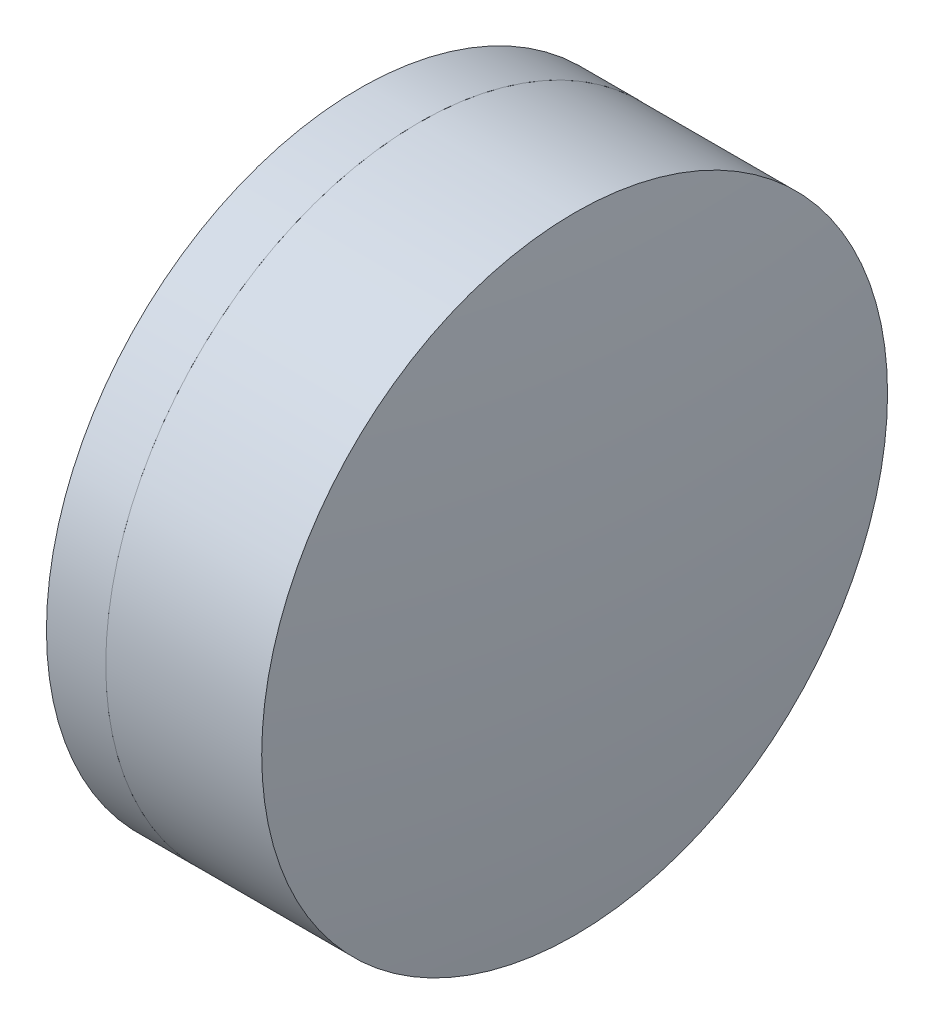
from build123d import *


with BuildPart() as part:
    # 草图1 one side → 旋转1 (revolve)
    with BuildSketch(Plane(origin=(0, 0, 0), x_dir=(1, 0, 0), z_dir=(0, 1, 0)), mode=Mode.PRIVATE) as revolve_1_sk:
        with BuildLine():
            ThreePointArc((18.49481299, 12.7), (15.669158782, 6.627382494), (14.700238586, 0))
            Line((14.700238586, 0), (26.200238586, 0))
            ThreePointArc((26.200238586, 0), (24.82254971, 6.880448662), (20.901909119, 12.7))
            Line((20.901909119, 12.7), (18.49481299, 12.7))
        make_face()
    revolve(revolve_1_sk.sketch.rotate(Axis((-0.816062176, 0, 0), (1, 0, 0)), 180), axis=Axis((-0.816062176, 0, 0), (1, 0, 0)))  # turned: the seam where the file's is


with BuildPart() as body_2:
    # 草图2 one side → 旋转2 (revolve)
    with BuildSketch(Plane(origin=(0, 0, 0), x_dir=(1, 0, 0), z_dir=(0, 1, 0)), mode=Mode.PRIVATE) as revolve_2_sk:
        with BuildLine():
            Line((27.23083755, 12.7), (20.901909119, 12.7))
            ThreePointArc((20.901909119, 12.7), (24.82254971, 6.880448662), (26.200238586, 0))
            Line((26.200238586, 0), (28.000238586, 0))
            ThreePointArc((28.000238586, 0), (27.807712156, 6.361642436), (27.23083755, 12.7))
        make_face()
    revolve(revolve_2_sk.sketch.rotate(Axis((-0.551919993, 0, 0), (1, 0, 0)), 180), axis=Axis((-0.551919993, 0, 0), (1, 0, 0)))  # turned: the seam where the file's is


solid = Compound([part.part, body_2.part])
